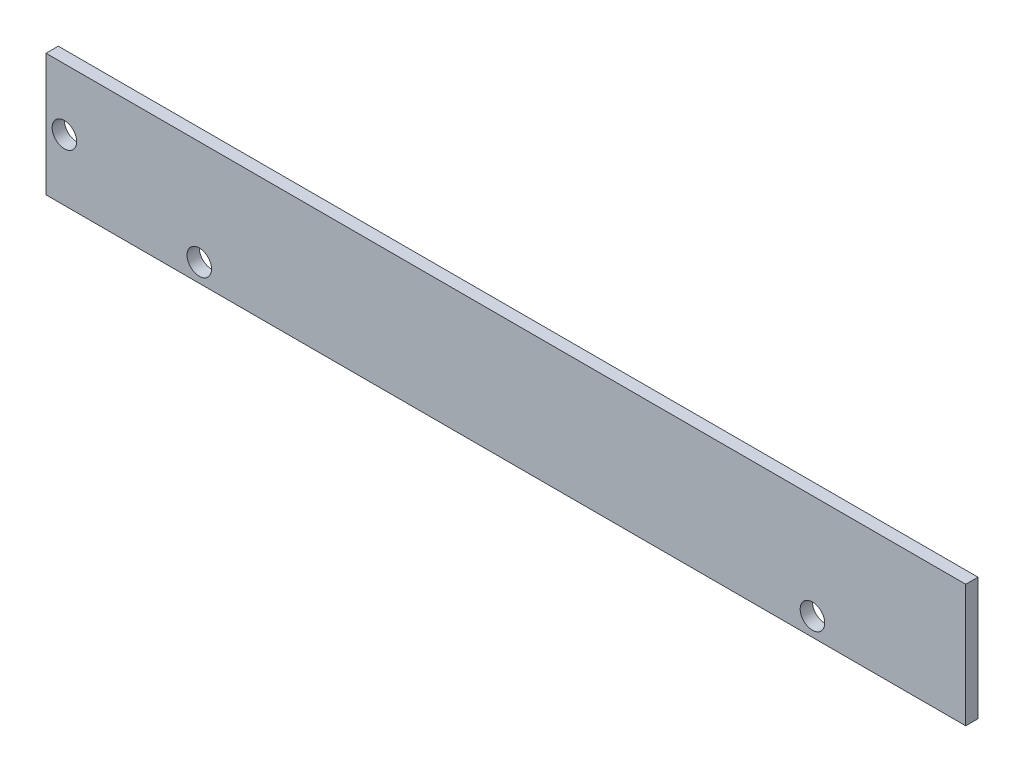
from build123d import *

# Parameters (mm, degrees)
SKETCH_1_W      = 150
SKETCH_1_H      = 20
SKETCH_1_R      = 2
EXTRUDE_2_DEPTH = 2


with BuildPart() as part:
    # 草图1 → 凸台-拉伸2 (new body)
    with BuildSketch(Plane.XY):
        Rectangle(SKETCH_1_W, SKETCH_1_H)
        with Locations((-50, -7)):
            Circle(SKETCH_1_R, mode=Mode.SUBTRACT)
        with Locations((50, -7)):
            Circle(SKETCH_1_R, mode=Mode.SUBTRACT)
        with Locations((-72, 0)):
            Circle(SKETCH_1_R, mode=Mode.SUBTRACT)
    extrude(amount=EXTRUDE_2_DEPTH)


solid = part.part
